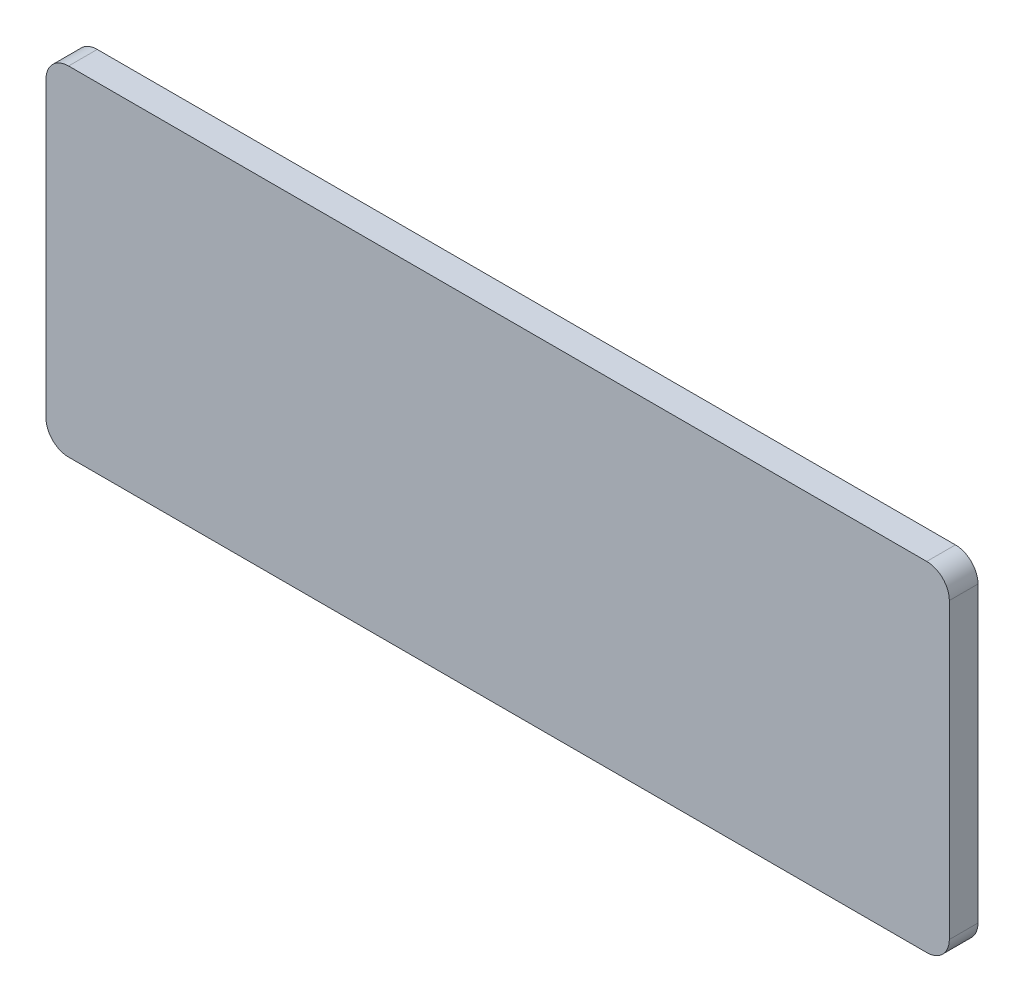
from build123d import *

# Parameters (mm, degrees)
SKETCH1_W           = 200
SKETCH1_H           = 75
BOSS_EXTRUDE1_DEPTH = 6.35
FILLET1_R           = 5


with BuildPart() as part:
    # Sketch1 → Boss-Extrude1 (new body)
    with BuildSketch(Plane.XY):
        Rectangle(SKETCH1_W, SKETCH1_H)
    extrude(amount=-BOSS_EXTRUDE1_DEPTH)

    # Fillet1
    fillet1_edges = [part.edges().sort_by_distance(p)[0] for p in [
        (100, -37.5, -3.175),
        (-100, -37.5, -3.175),
        (-100, 37.5, -3.175),
        (100, 37.5, -3.175),
    ]]
    fillet(fillet1_edges, radius=FILLET1_R)


solid = part.part
